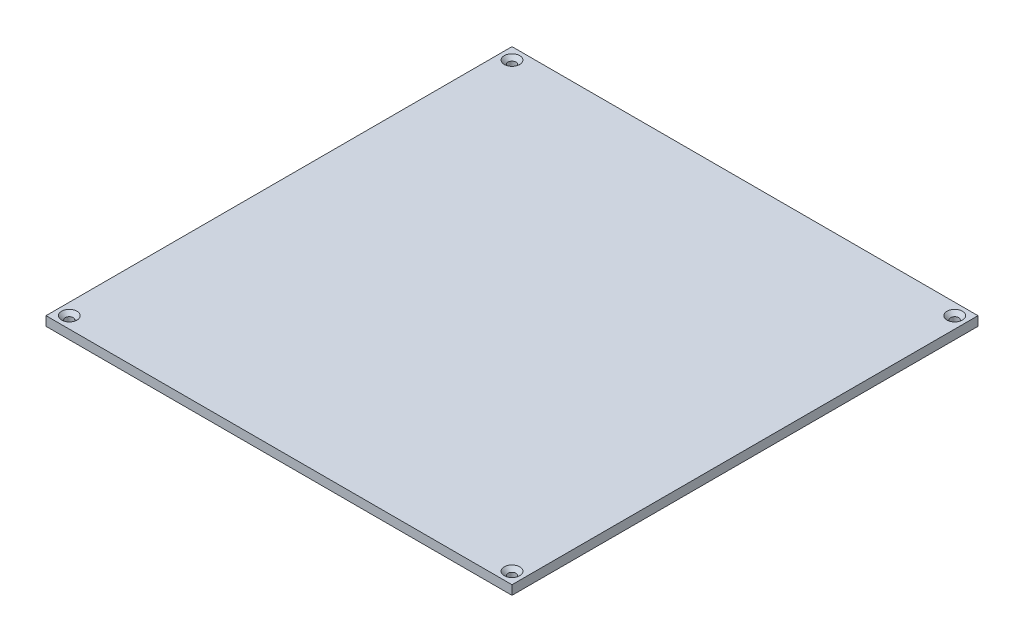
from build123d import *

# Parameters (mm, degrees)
SKETCH1_W                                       = 320
SKETCH1_H                                       = 320
SKETCH1_R                                       = 2.525
BOSS_EXTRUDE1_DEPTH                             = 6.35
CSK_FOR_M5_FLAT_HEAD_MACHINE_SCREW1_D           = 5.5
CSK_FOR_M5_FLAT_HEAD_MACHINE_SCREW1_DEPTH       = 6.35
CSK_FOR_M5_FLAT_HEAD_MACHINE_SCREW1_CSINK_D     = 10.6
CSK_FOR_M5_FLAT_HEAD_MACHINE_SCREW1_CSINK_ANGLE = 90


with BuildPart() as part:
    # Sketch1 → Boss-Extrude1 (new body)
    with BuildSketch(Plane(origin=(0, 0, 0), x_dir=(1, 0, 0), z_dir=(0, 1, 0))):
        Rectangle(SKETCH1_W, SKETCH1_H)
        with Locations((152, 152)):
            Circle(SKETCH1_R, mode=Mode.SUBTRACT)
        with Locations((-152, -152)):
            Circle(SKETCH1_R, mode=Mode.SUBTRACT)
        with Locations((152, -152)):
            Circle(SKETCH1_R, mode=Mode.SUBTRACT)
        with Locations((-152, 152)):
            Circle(SKETCH1_R, mode=Mode.SUBTRACT)
    extrude(amount=-BOSS_EXTRUDE1_DEPTH)

    # CSK for M5 Flat Head Machine Screw1
    with Locations(Plane(origin=(-152, 0, -152), x_dir=(0, 0, 1), z_dir=(0, 1, 0))):
        with Locations((0, 0), (0, 304), (304, 304), (304, 0)):
            CounterSinkHole(CSK_FOR_M5_FLAT_HEAD_MACHINE_SCREW1_D / 2, CSK_FOR_M5_FLAT_HEAD_MACHINE_SCREW1_CSINK_D / 2, depth=CSK_FOR_M5_FLAT_HEAD_MACHINE_SCREW1_DEPTH, counter_sink_angle=CSK_FOR_M5_FLAT_HEAD_MACHINE_SCREW1_CSINK_ANGLE)


solid = part.part
